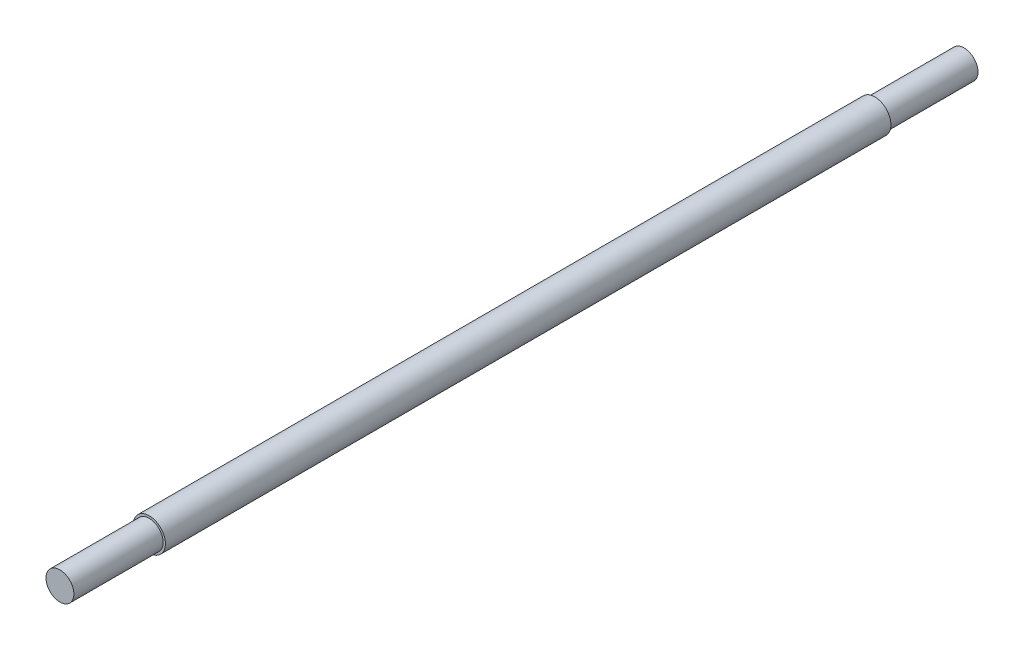
from build123d import *

# Parameters (mm, degrees)
SKETCH1_R           = 14.5
BOSS_EXTRUDE1_DEPTH = 325
SKETCH2_R           = 12.5
BOSS_EXTRUDE2_DEPTH = 80


with BuildPart() as part:
    # Sketch1 → Boss-Extrude1 (new body, symmetric)
    with BuildSketch(Plane.XY):
        Circle(SKETCH1_R)
    extrude(amount=BOSS_EXTRUDE1_DEPTH, both=True)


with BuildPart() as body_2:
    # Sketch2 → Boss-Extrude2 (new body)
    with BuildSketch(Plane.XY.offset(325)):
        Circle(SKETCH2_R)
    extrude(amount=BOSS_EXTRUDE2_DEPTH)


with BuildPart() as body_3:
    # Mirror1: mirrored copy
    add(body_2.part.mirror(Plane.XY))


solid = Compound([part.part, body_2.part, body_3.part])
